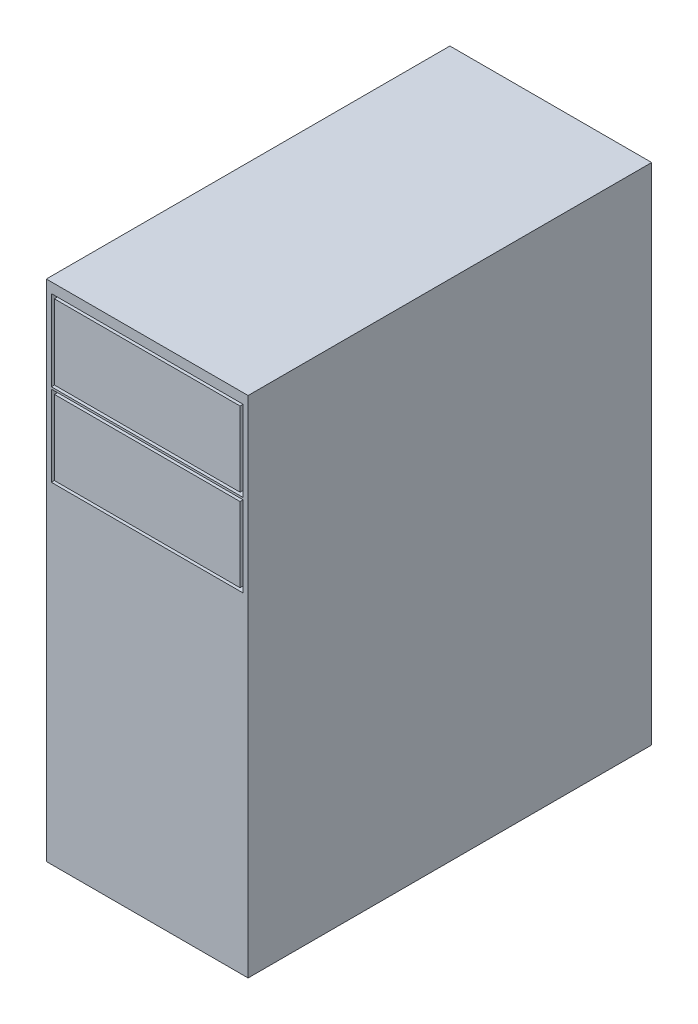
from build123d import *

# Parameters (mm, degrees)
SKETCH1_W           = 50
SKETCH1_H           = 100
BOSS_EXTRUDE1_DEPTH = 125
SKETCH2_W           = 47.5
SKETCH2_H           = 20
SKETCH2_W_2         = 46
SKETCH2_H_2         = 18.5
CUT_EXTRUDE1_DEPTH  = 2


with BuildPart() as part:
    # Sketch1 → Boss-Extrude1 (new body)
    with BuildSketch(Plane(origin=(0, 0, 0), x_dir=(1, 0, 0), z_dir=(0, 1, 0))):
        Rectangle(SKETCH1_W, SKETCH1_H)
    extrude(amount=BOSS_EXTRUDE1_DEPTH)

    # Sketch2 → Cut-Extrude1 (cut)
    with BuildSketch(Plane.XY.offset(50)):
        with Locations((0, 112.5)):
            Rectangle(SKETCH2_W, SKETCH2_H)
        with Locations((0, 112.5)):
            Rectangle(SKETCH2_W_2, SKETCH2_H_2, mode=Mode.SUBTRACT)
        with Locations((0, 92)):
            Rectangle(SKETCH2_W, SKETCH2_H)
        with Locations((0, 92)):
            Rectangle(SKETCH2_W_2, SKETCH2_H_2, mode=Mode.SUBTRACT)
    extrude(amount=-CUT_EXTRUDE1_DEPTH, mode=Mode.SUBTRACT)


solid = part.part
